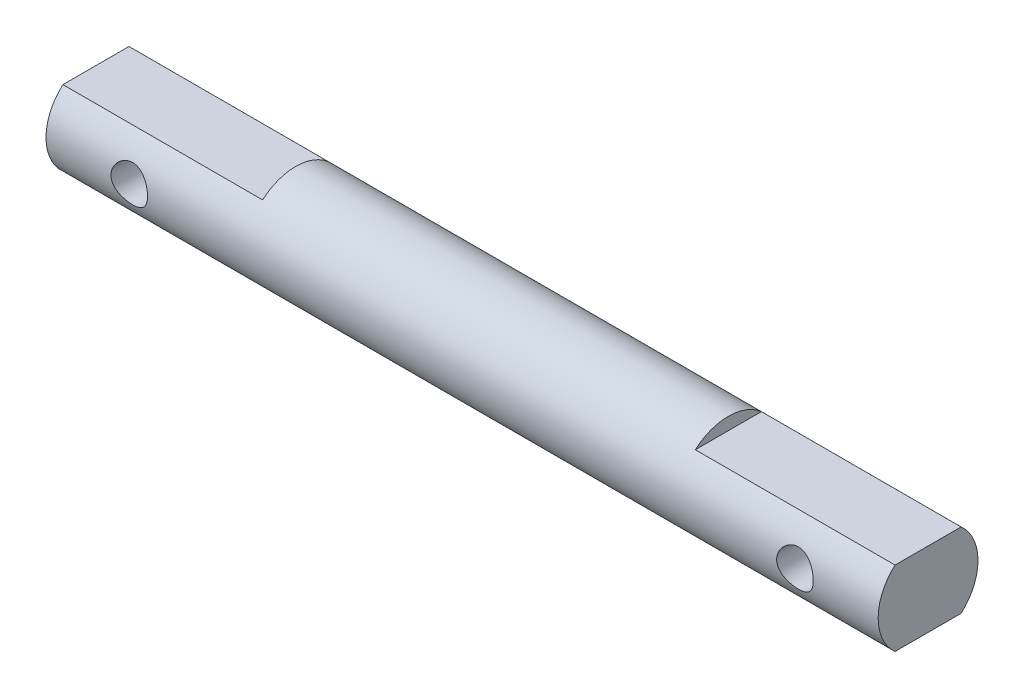
from build123d import *

# Parameters (mm, degrees)
SKETCH1_W               = 50
SKETCH1_H               = 3
SKETCH2_W               = 12
SKETCH2_H               = 0.75
CUT_EXTRUDE1_DEPTH      = 4
CUT_EXTRUDE1_DEPTH_BACK = 4
SKETCH3_R               = 1.1
CUT_EXTRUDE2_DEPTH      = 4
CUT_EXTRUDE2_DEPTH_BACK = 4


with BuildPart() as part:
    # Sketch1 → Revolve1 (revolve)
    with BuildSketch(Plane.XY):
        with Locations((0, 1.5)):
            Rectangle(SKETCH1_W, SKETCH1_H)
    revolve(axis=Axis((0, 0, 0), (1, 0, 0)))

    # Sketch2 → Cut-Extrude1 (cut, two sides)
    with BuildSketch(Plane.XY) as cut_extrude1_sk:
        with Locations((-19, 2.625)):
            Rectangle(SKETCH2_W, SKETCH2_H)
        with Locations((-19, -2.625)):
            Rectangle(SKETCH2_W, SKETCH2_H)
        with Locations((19, 2.625)):
            Rectangle(SKETCH2_W, SKETCH2_H)
        with Locations((19, -2.625)):
            Rectangle(SKETCH2_W, SKETCH2_H)
    extrude(amount=CUT_EXTRUDE1_DEPTH, mode=Mode.SUBTRACT)
    extrude(cut_extrude1_sk.sketch, amount=-CUT_EXTRUDE1_DEPTH_BACK, mode=Mode.SUBTRACT)

    # Sketch3 → Cut-Extrude2 (cut, two sides)
    with BuildSketch(Plane.XY) as cut_extrude2_sk:
        with Locations((-20, 0)):
            Circle(SKETCH3_R)
        with Locations((20, 0)):
            Circle(SKETCH3_R)
    extrude(amount=CUT_EXTRUDE2_DEPTH, mode=Mode.SUBTRACT)
    extrude(cut_extrude2_sk.sketch, amount=-CUT_EXTRUDE2_DEPTH_BACK, mode=Mode.SUBTRACT)


solid = part.part
